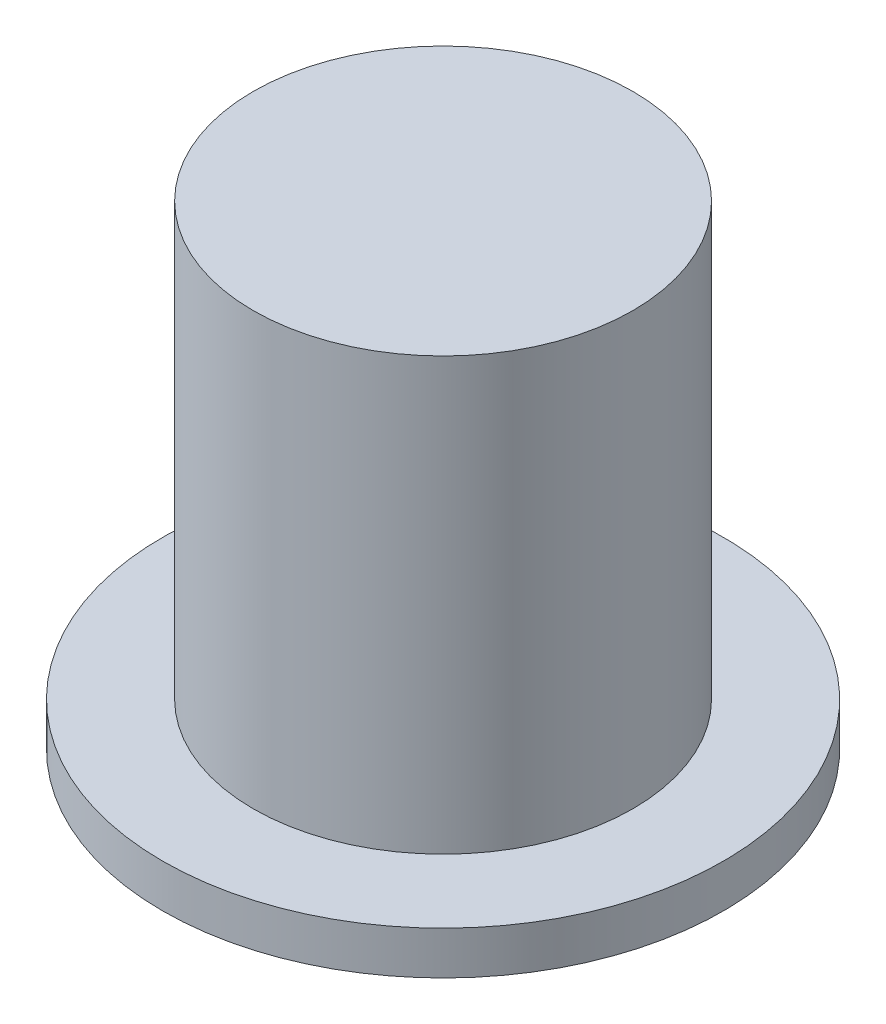
from build123d import *

# Parameters (mm, degrees)
SKETCH1_R           = 3.25
BOSS_EXTRUDE1_DEPTH = 0.5
SKETCH2_R           = 2.2
BOSS_EXTRUDE2_DEPTH = 5


with BuildPart() as part:
    # Sketch1 → Boss-Extrude1 (new body)
    with BuildSketch(Plane(origin=(0, 0, 0), x_dir=(1, 0, 0), z_dir=(0, 1, 0))):
        Circle(SKETCH1_R)
    extrude(amount=BOSS_EXTRUDE1_DEPTH)

    # Sketch2 → Boss-Extrude2 (add)
    with BuildSketch(Plane(origin=(0, 0.5, 0), x_dir=(1, 0, 0), z_dir=(0, 1, 0))):
        Circle(SKETCH2_R)
    extrude(amount=BOSS_EXTRUDE2_DEPTH)


solid = part.part
